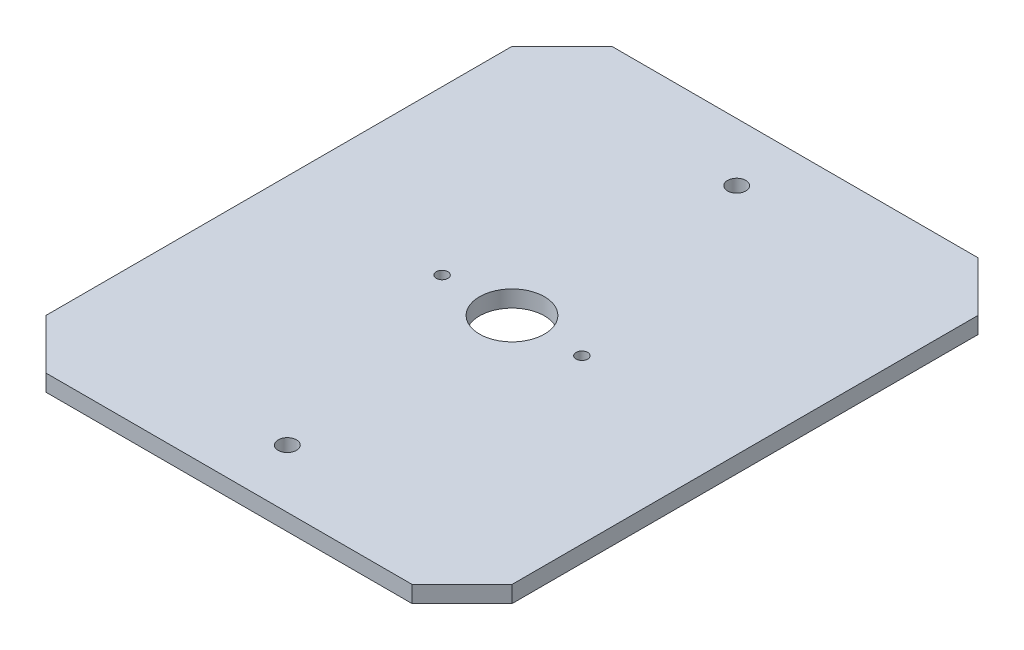
from build123d import *

# Parameters (mm, degrees)
SKETCH1_W           = 140
SKETCH1_H           = 170
BOSS_EXTRUDE1_DEPTH = 5
CHAMFER1_SIZE       = 15
SKETCH2_R           = 9.75
CUT_EXTRUDE1_DEPTH  = 5
SKETCH3_R           = 2.75
CUT_EXTRUDE2_DEPTH  = 40
SKETCH4_R           = 1.75
CUT_EXTRUDE3_DEPTH  = 6


with BuildPart() as part:
    # Sketch1 → Boss-Extrude1 (new body)
    with BuildSketch(Plane(origin=(0, 0, 0), x_dir=(1, 0, 0), z_dir=(0, 1, 0))):
        Rectangle(SKETCH1_W, SKETCH1_H)
    extrude(amount=BOSS_EXTRUDE1_DEPTH)

    # Chamfer1
    chamfer1_edges = [part.edges().sort_by_distance(p)[0] for p in [
        (-70, 2.5, -85),
        (70, 2.5, -85),
        (70, 2.5, 85),
        (-70, 2.5, 85),
    ]]
    chamfer(chamfer1_edges, length=CHAMFER1_SIZE)

    # Sketch2 → Cut-Extrude1 (cut)
    with BuildSketch(Plane(origin=(0, 5, 0), x_dir=(1, 0, 0), z_dir=(0, 1, 0))):
        Circle(SKETCH2_R)
    extrude(amount=-CUT_EXTRUDE1_DEPTH, mode=Mode.SUBTRACT)

    # Sketch3 → Cut-Extrude2 (cut)
    with BuildSketch(Plane(origin=(0, 5, 0), x_dir=(1, 0, 0), z_dir=(0, 1, 0))):
        with Locations((0, -67.5)):
            Circle(SKETCH3_R)
        with Locations((0, 67.5)):
            Circle(SKETCH3_R)
    extrude(amount=-CUT_EXTRUDE2_DEPTH, mode=Mode.SUBTRACT)

    # Sketch4 → Cut-Extrude3 (cut, through all)
    with BuildSketch(Plane(origin=(0, 5, 0), x_dir=(1, 0, 0), z_dir=(0, 1, 0))):
        with Locations((-21, 0)):
            Circle(SKETCH4_R)
        with Locations((21, 0)):
            Circle(SKETCH4_R)
    extrude(amount=-CUT_EXTRUDE3_DEPTH, mode=Mode.SUBTRACT)


solid = part.part
